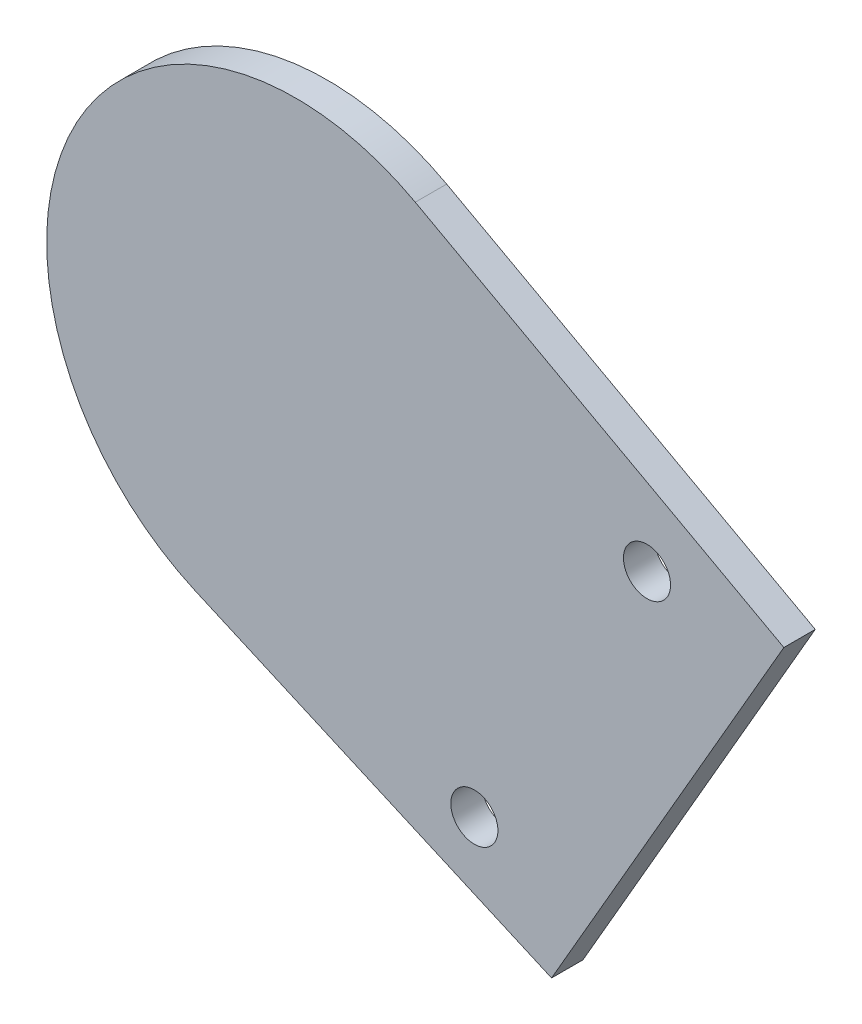
from build123d import *

# Parameters (mm, degrees)
BOSS_EXTRUDE1_DEPTH = 1
SKETCH1_3_R         = 1.5
BOSS_EXTRUDE2_DEPTH = 2


with BuildPart() as part:
    # Sketch1 → Boss-Extrude1 (new body)
    with BuildSketch(Plane.XY):
        with BuildLine():
            ThreePointArc((13.84093453, 33.361395308), (13.331800916, 34.427699543), (12.569519065, 35.330555089))
            Line((12.569519065, 35.330555089), (6.207550462, 41.160225249))
            ThreePointArc((6.207550462, 41.160225249), (-17.81741665, 47.650937168), (-0.183811683, 30.090061284))
            Line((-0.183811683, 30.090061284), (8.045815072, 27.495269935))
            ThreePointArc((8.045815072, 27.495269935), (10.806658392, 27.487211768), (13.081997543, 29.050910113))
            Line((13.081997543, 29.050910113), (13.84093453, 33.361395308))
        make_face()
    extrude(amount=-BOSS_EXTRUDE1_DEPTH)

    # Sketch1_3 → Boss-Extrude2 (add)
    with BuildSketch(Plane.XY):
        with BuildLine():
            Line((9.627757266, 16.675764747), (15.778866438, 27.329798357))
            Line((15.778866438, 27.329798357), (18.278866438, 31.659925376))
            Line((18.278866438, 31.659925376), (24.429975611, 42.313958986))
            Line((24.429975611, 42.313958986), (0.94372521, 55.144959619))
            ThreePointArc((0.94372521, 55.144959619), (-20.908315232, 48.228438049), (-13.073721217, 26.688496574))
            Line((-13.073721217, 26.688496574), (9.627757266, 16.675764747))
        make_face()
        with Locations((4.709200809, 23.09818313)):
            Circle(SKETCH1_3_R, mode=Mode.SUBTRACT)
        with Locations((15.709200809, 42.150742014)):
            Circle(SKETCH1_3_R, mode=Mode.SUBTRACT)
    extrude(amount=BOSS_EXTRUDE2_DEPTH)


solid = part.part
